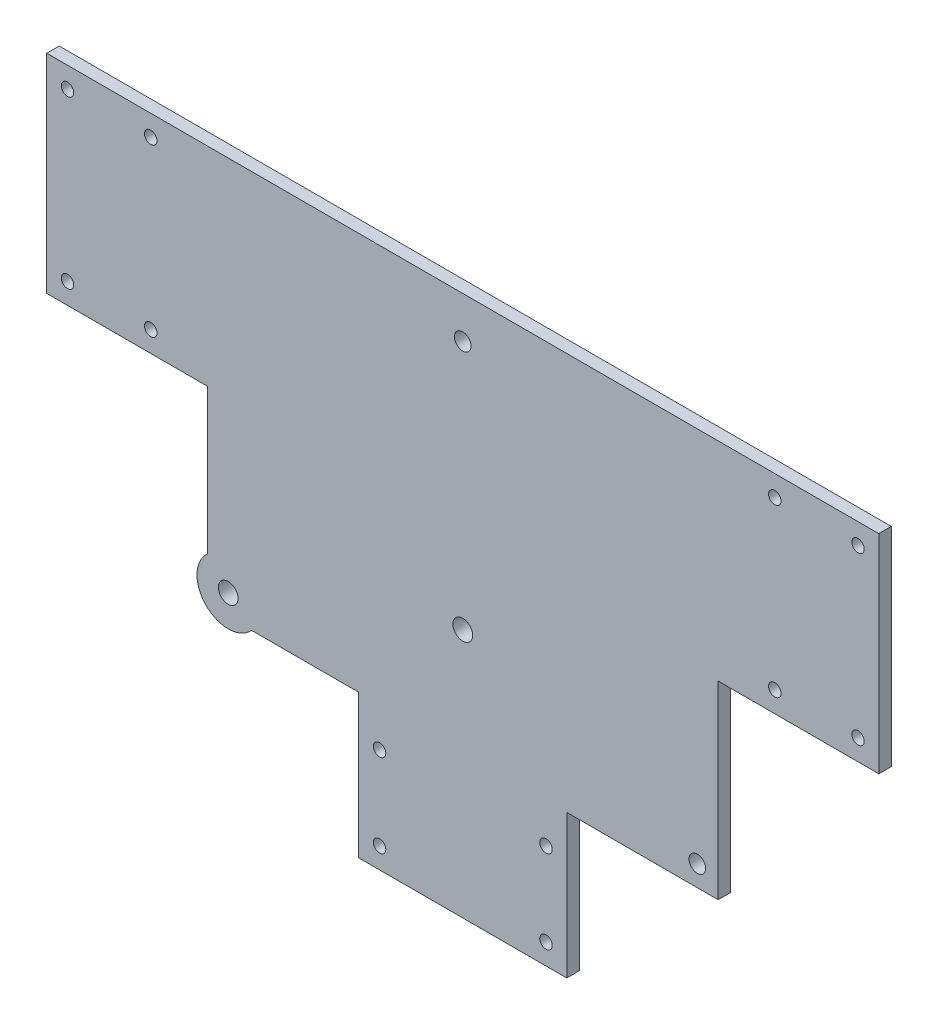
from build123d import *

# Parameters (mm, degrees)
ESQUISSE1_R             = 2
ESQUISSE1_R_2           = 1.5
BOSS_EXTRU_1_DEPTH      = 3
BOSS_EXTRU_2_START      = -3
ESQUISSE3_R             = 7.5
BOSS_EXTRU_2_DEPTH      = 6
ESQUISSE4_R             = 3.875
ENL_V_MAT_EXTRU_1_DEPTH = 1
ESQUISSE5_R             = 2.375
ENL_V_MAT_EXTRU_2_DEPTH = 4
ENL_V_MAT_EXTRU_3_REACH = 3
ESQUISSE6_R             = 2.375


with BuildPart() as part:
    # Esquisse1 → Boss.-Extru.1 (new body)
    with BuildSketch(Plane.XY):
        Polygon((0, 50), (-100, 50), (-100, 0), (-61.381557247, 0), (-61.381557247, -45.5212086), (-25, -45.5212086), (-25, -80), (25, -80), (25, -45.5212086), (61.381557247, -45.5212086), (61.381557247, 0), (100, 0), (100, 50), align=None)
        with Locations((0, 20)):
            Circle(ESQUISSE1_R, mode=Mode.SUBTRACT)
        with Locations((0, -20)):
            Circle(ESQUISSE1_R, mode=Mode.SUBTRACT)
        with Locations((0, 40)):
            Circle(ESQUISSE1_R, mode=Mode.SUBTRACT)
        with Locations((-20, -55)):
            Circle(ESQUISSE1_R_2, mode=Mode.SUBTRACT)
        with Locations((20, -55)):
            Circle(ESQUISSE1_R_2, mode=Mode.SUBTRACT)
        with Locations((20, -75)):
            Circle(ESQUISSE1_R_2, mode=Mode.SUBTRACT)
        with Locations((-20, -75)):
            Circle(ESQUISSE1_R_2, mode=Mode.SUBTRACT)
        with Locations((-95, 45)):
            Circle(ESQUISSE1_R_2, mode=Mode.SUBTRACT)
        with Locations((-75, 45)):
            Circle(ESQUISSE1_R_2, mode=Mode.SUBTRACT)
        with Locations((-75, 5)):
            Circle(ESQUISSE1_R_2, mode=Mode.SUBTRACT)
        with Locations((-95, 5)):
            Circle(ESQUISSE1_R_2, mode=Mode.SUBTRACT)
        with Locations((75, 5)):
            Circle(ESQUISSE1_R_2, mode=Mode.SUBTRACT)
        with Locations((95, 5)):
            Circle(ESQUISSE1_R_2, mode=Mode.SUBTRACT)
        with Locations((75, 45)):
            Circle(ESQUISSE1_R_2, mode=Mode.SUBTRACT)
        with Locations((95, 45)):
            Circle(ESQUISSE1_R_2, mode=Mode.SUBTRACT)
        with Locations((56.381557247, -40.5212086)):
            Circle(ESQUISSE1_R, mode=Mode.SUBTRACT)
        with Locations((-56.381557247, -40.5212086)):
            Circle(ESQUISSE1_R, mode=Mode.SUBTRACT)
    extrude(amount=BOSS_EXTRU_1_DEPTH)

    # Esquisse3 → Boss.-Extru.2 (add)
    with BuildSketch(Plane(origin=(0, 0, 0), x_dir=(-1, 0, 0), z_dir=(0, 0, -1)).offset(BOSS_EXTRU_2_START)):
        with Locations((0, 20)):
            Circle(ESQUISSE3_R)
        with Locations((56.381557247, -40.5212086)):
            Circle(ESQUISSE3_R)
        with Locations((0, -20)):
            Circle(ESQUISSE3_R)
    extrude(amount=BOSS_EXTRU_2_DEPTH)

    # Esquisse4 → Enlèv. mat.-Extru.1 (cut)
    with BuildSketch(Plane(origin=(0, 0, -3), x_dir=(-1, 0, 0), z_dir=(0, 0, -1))):
        with Locations((56.381557247, -40.5212086)):
            Circle(ESQUISSE4_R)
        with Locations((0, 20)):
            Circle(ESQUISSE4_R)
        with Locations((0, -20)):
            Circle(ESQUISSE4_R)
    extrude(amount=-ENL_V_MAT_EXTRU_1_DEPTH, mode=Mode.SUBTRACT)

    # Esquisse5 → Enlèv. mat.-Extru.2 (cut)
    with BuildSketch(Plane(origin=(0, 0, -2), x_dir=(-1, 0, 0), z_dir=(0, 0, -1))):
        with Locations((56.381557247, -40.5212086)):
            Circle(ESQUISSE5_R)
        with Locations((0, 20)):
            Circle(ESQUISSE5_R)
        with Locations((0, -20)):
            Circle(ESQUISSE5_R)
    extrude(amount=-ENL_V_MAT_EXTRU_2_DEPTH, mode=Mode.SUBTRACT)

    # Esquisse6 → Enlèv. mat.-Extru.3 (cut, up to next)
    with BuildSketch(Plane(origin=(0, 0, 2), x_dir=(-1, 0, 0), z_dir=(0, 0, -1)), mode=Mode.PRIVATE) as enl_v_mat_extru_3_sk1:
        with Locations((56.381557247, -40.5212086)):
            Circle(ESQUISSE6_R)
    enl_v_mat_extru_3_tool1 = extrude(enl_v_mat_extru_3_sk1.sketch, amount=-ENL_V_MAT_EXTRU_3_REACH, mode=Mode.PRIVATE) & part.part
    add(enl_v_mat_extru_3_tool1.solids().sort_by_distance((-56.381557, -40.521209, 2))[0], mode=Mode.SUBTRACT)
    # Esquisse6 → Enlèv. mat.-Extru.3 (cut, up to next)
    with BuildSketch(Plane(origin=(0, 0, 2), x_dir=(-1, 0, 0), z_dir=(0, 0, -1)), mode=Mode.PRIVATE) as enl_v_mat_extru_3_sk2:
        with Locations((0, -20)):
            Circle(ESQUISSE6_R)
    enl_v_mat_extru_3_tool2 = extrude(enl_v_mat_extru_3_sk2.sketch, amount=-ENL_V_MAT_EXTRU_3_REACH, mode=Mode.PRIVATE) & part.part
    add(enl_v_mat_extru_3_tool2.solids().sort_by_distance((0, -20, 2))[0], mode=Mode.SUBTRACT)


solid = part.part
